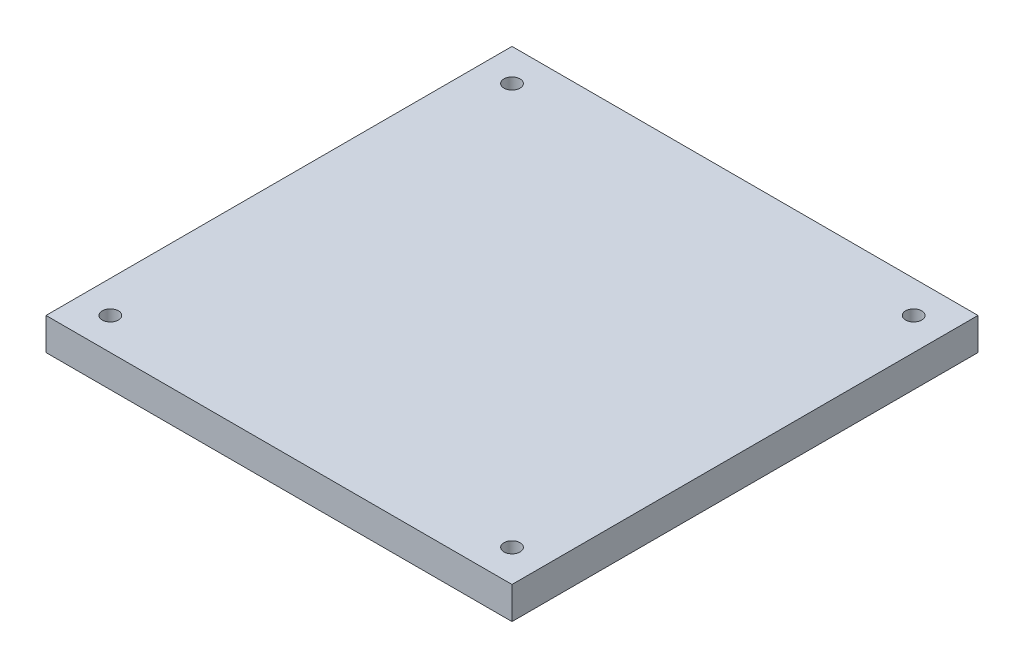
from build123d import *

# Parameters (mm, degrees)
SKETCH1_W           = 91.975321777
SKETCH1_H           = 91.975321776
SKETCH1_R           = 1.5875
BOSS_EXTRUDE1_DEPTH = 6.35


with BuildPart() as part:
    # Sketch1 → Boss-Extrude1 (new body)
    with BuildSketch(Plane(origin=(0, 0, 0), x_dir=(1, 0, 0), z_dir=(0, 1, 0))):
        with Locations((8.667485449, -11.496549638)):
            Rectangle(SKETCH1_W, SKETCH1_H)
        with Locations((-30.970175439, 28.14111125)):
            Circle(SKETCH1_R, mode=Mode.SUBTRACT)
        with Locations((48.305146338, 28.14111125)):
            Circle(SKETCH1_R, mode=Mode.SUBTRACT)
        with Locations((-30.970175439, -51.134210526)):
            Circle(SKETCH1_R, mode=Mode.SUBTRACT)
        with Locations((48.305146338, -51.134210526)):
            Circle(SKETCH1_R, mode=Mode.SUBTRACT)
    extrude(amount=BOSS_EXTRUDE1_DEPTH)


solid = part.part
